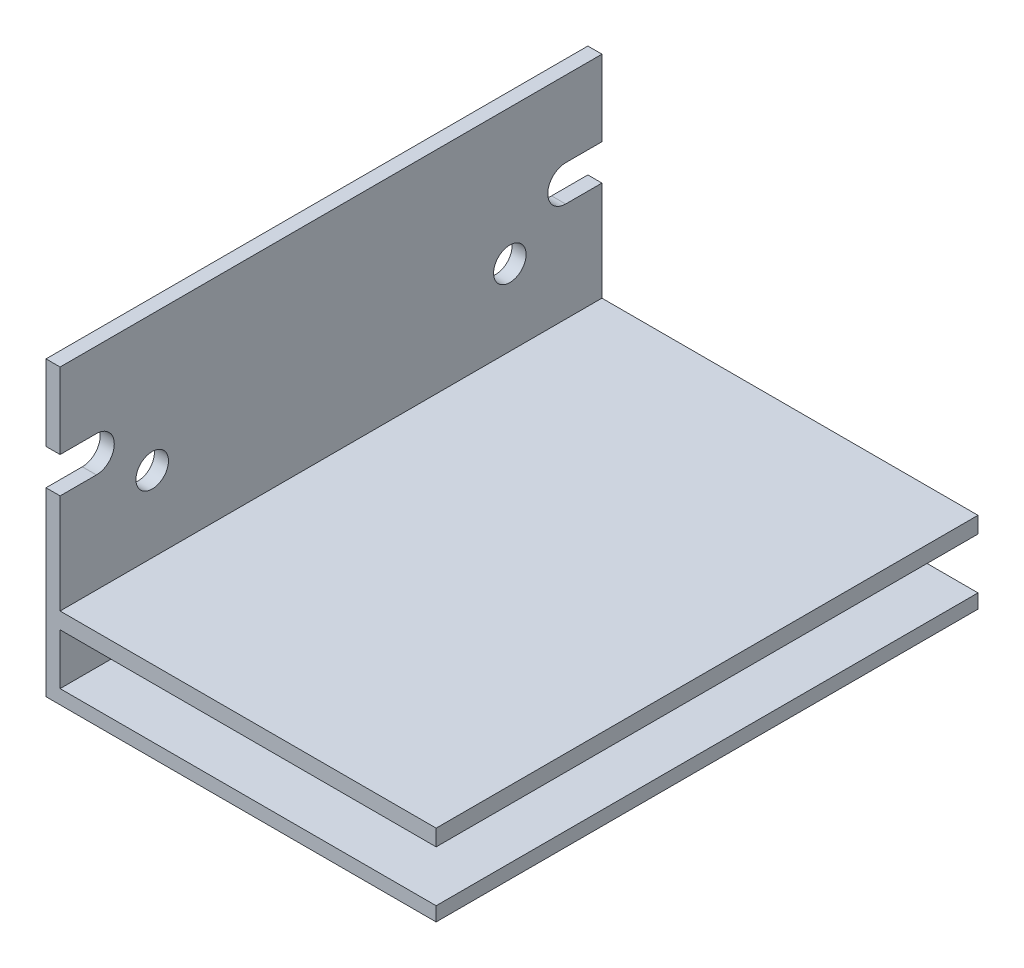
from build123d import *

# Parameters (mm, degrees)
RESSALTO_EXTRUS_O1_DEPTH = 50
ESBO_O2_R                = 1.5
CORTE_EXTRUS_O1_DEPTH    = 50


with BuildPart() as part:
    # Esboço1 → Ressalto-extrusão1 (new body)
    with BuildSketch(Plane.XY):
        Polygon((0, 0), (0, 27), (1.3, 27), (1.3, 7.5), (36, 7.5), (36, 6), (1.3, 6), (1.3, 1.3), (36, 1.3), (36, 0), align=None)
    extrude(amount=RESSALTO_EXTRUS_O1_DEPTH)

    # Esboço2 → Corte-extrusão1 (cut)
    with BuildSketch(Plane.ZY):
        with Locations((8.5, 14.5)):
            Circle(ESBO_O2_R)
        with Locations((41.5, 14.5)):
            Circle(ESBO_O2_R)
        with BuildLine():
            Line((0, 20), (3.35, 20))
            ThreePointArc((3.35, 20), (5, 18.35), (3.35, 16.7))
            Line((3.35, 16.7), (0, 16.7))
            Line((0, 16.7), (0, 20))
        make_face()
        with BuildLine():
            Line((50, 16.7), (50, 20))
            Line((50, 20), (46.65, 20))
            ThreePointArc((46.65, 20), (45, 18.35), (46.65, 16.7))
            Line((46.65, 16.7), (50, 16.7))
        make_face()
    extrude(amount=-CORTE_EXTRUS_O1_DEPTH, mode=Mode.SUBTRACT)


solid = part.part
